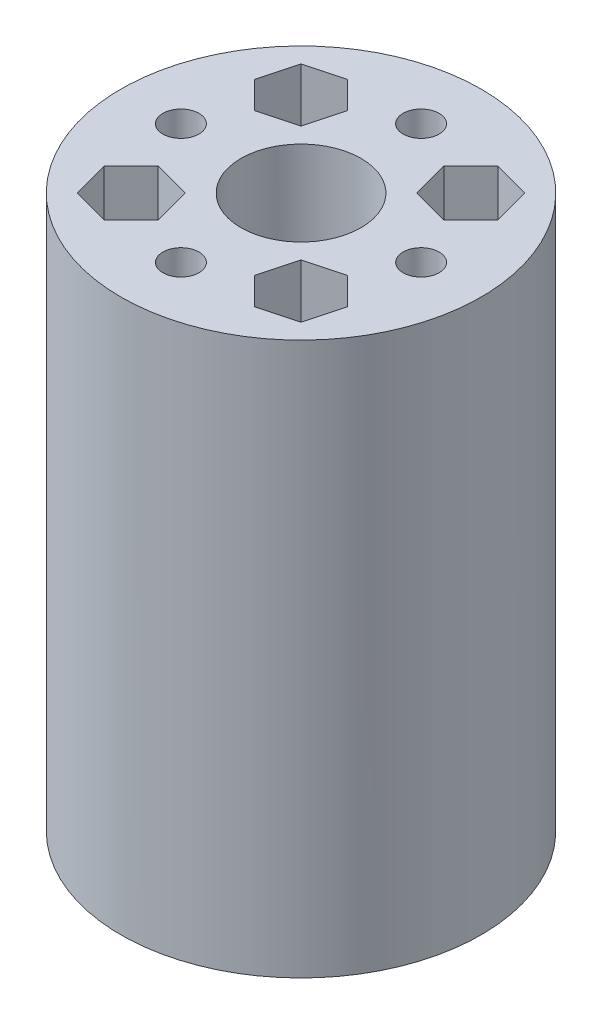
from build123d import *

# Parameters (mm, degrees)
SKETCH_1_R               = 15
SKETCH_1_R_2             = 5
EXTRUDE_4_DEPTH          = 3
SKETCH_1_R_3             = 3.5
SKETCH_1_R_4             = 2.1
EXTRUDE_4_2_DEPTH        = 3
EXTRUDE_5_DEPTH          = 3
PATTERN_CIRCULAR_2_COUNT = 4
SKETCH_6_R               = 3.5
SKETCH_6_R_2             = 2.1
EXTRUDE_6_DEPTH          = 3
PATTERN_CIRCULAR_3_COUNT = 4
SKETCH_7_R               = 15
SKETCH_7_R_2             = 5
EXTRUDE_7_DEPTH          = 46
CUT_EXTRUDE_1_DEPTH      = 46
PATTERN_CIRCULAR_4_COUNT = 4
SKETCH_11_R              = 1.5
CUT_EXTRUDE_2_DEPTH      = 3
PATTERN_CIRCULAR_5_COUNT = 4
EXTRUDE_8_DEPTH          = 3
EXTRUDE_9_DEPTH          = 3
EXTRUDE_10_DEPTH         = 3
EXTRUDE_11_DEPTH         = 3
EXTRUDE_13_DEPTH         = 3
EXTRUDE_14_DEPTH         = 3
CUT_EXTRUDE_3_DEPTH      = 2.5
SKETCH_19_R              = 1.5
CUT_EXTRUDE_4_DEPTH      = 2.5
SKETCH_20_R              = 1.5
CUT_EXTRUDE_5_DEPTH      = 2.5
SKETCH_21_R              = 15
SKETCH_21_R_2            = 5
EXTRUDE_15_DEPTH         = 3
SKETCH_22_R              = 1.5
CUT_EXTRUDE_6_DEPTH      = 3
PATTERN_CIRCULAR_6_COUNT = 4
EXTRUDE_16_DEPTH         = 3
CUT_EXTRUDE_7_DEPTH      = 3
SKETCH_25_R              = 15
SKETCH_25_R_2            = 5
EXTRUDE_17_DEPTH         = 43
SKETCH_27_R              = 1.5
CUT_EXTRUDE_8_DEPTH      = 46
SKETCH_28_R              = 2.75
CUT_EXTRUDE_9_DEPTH      = 43
SKETCH_29_R              = 1.5
CUT_EXTRUDE_10_DEPTH     = 46
PATTERN_CIRCULAR_7_COUNT = 4
CUT_EXTRUDE_11_DEPTH     = 43
PATTERN_CIRCULAR_8_COUNT = 4
SKETCH_31_R              = 35.862393663
CUT_EXTRUDE_12_DEPTH     = 100


with BuildPart() as part:
    # 草图1 → 凸台-拉伸4 (new body)
    with BuildSketch(Plane(origin=(0, 0, 0), x_dir=(1, 0, 0), z_dir=(0, 1, 0))):
        with Locations((-5.372895461, -8.931727747)):
            Circle(SKETCH_1_R)
        with Locations((-5.372895461, -8.931727747)):
            Circle(SKETCH_1_R_2, mode=Mode.SUBTRACT)
    extrude(amount=EXTRUDE_4_DEPTH)



with BuildPart() as body_2:
    # 草图1 → Extrude 4 2 (new body)
    with BuildSketch(Plane(origin=(0, 0, 0), x_dir=(1, 0, 0), z_dir=(0, 1, 0))):
        with Locations((-22.372895461, 8.068272253)):
            Circle(SKETCH_1_R_3)
        with Locations((-22.372895461, 8.068272253)):
            Circle(SKETCH_1_R_4, mode=Mode.SUBTRACT)
    extrude(amount=EXTRUDE_4_2_DEPTH)


with BuildPart() as part_1:
    add(part.part)

    add(body_2.part)  # 凸台-拉伸5 merges body 2
    # 草图5 → 凸台-拉伸5 (add)
    with BuildSketch(Plane(origin=(0, 0, 0), x_dir=(1, 0, 0), z_dir=(0, 1, 0))):
        Polygon((-22.372895461, 4.568272253), (-10.372895461, -8.931727747), (-10.372895461, -3.931727747), (-5.372895461, -3.931727747), (-18.872895461, 8.068272253), align=None)
    extrude_5 = extrude(amount=EXTRUDE_5_DEPTH)

    # 阵列(圆周)2: 凸台-拉伸5 ×4 about axis
    pattern_circular_2_axis = Axis((-5.372895461, 0, 8.931727747), (0, 1, 0))
    for i in range(1, PATTERN_CIRCULAR_2_COUNT):
        add(extrude_5.rotate(pattern_circular_2_axis, i * 360 / PATTERN_CIRCULAR_2_COUNT))

    # 草图6 → 凸台-拉伸6 (add)
    with BuildSketch(Plane(origin=(0, 3, 0), x_dir=(1, 0, 0), z_dir=(0, 1, 0))):
        with Locations((11.627104539, 8.068272253)):
            Circle(SKETCH_6_R)
        with Locations((11.627104539, 8.068272253)):
            Circle(SKETCH_6_R_2, mode=Mode.SUBTRACT)
    extrude_6 = extrude(amount=-EXTRUDE_6_DEPTH)

    # 阵列(圆周)3: 凸台-拉伸6 ×4 about axis
    pattern_circular_3_axis = Axis((-5.372895461, 0, 8.931727747), (0, 1, 0))
    for i in range(1, PATTERN_CIRCULAR_3_COUNT):
        add(extrude_6.rotate(pattern_circular_3_axis, i * 360 / PATTERN_CIRCULAR_3_COUNT))

    # 草图7 → 凸台-拉伸7 (add)
    with BuildSketch(Plane.XZ):
        with Locations((-5.372895461, 8.931727747)):
            Circle(SKETCH_7_R)
        with Locations((-5.372895461, 8.931727747)):
            Circle(SKETCH_7_R_2, mode=Mode.SUBTRACT)
    extrude(amount=EXTRUDE_7_DEPTH)

    # 草图9 → 切除-拉伸1 (cut)
    with BuildSketch(Plane(origin=(0, 3, 0), x_dir=(1, 0, 0), z_dir=(0, 1, 0))):
        Polygon((0.876311502, -19.070022006), (-1.369054096, -16.824656408), (-0.547193246, -13.757429961), (2.520033201, -12.935569112), (4.765398798, -15.180934709), (3.943537949, -18.248161156), align=None)
    cut_extrude_1 = extrude(amount=-CUT_EXTRUDE_1_DEPTH, mode=Mode.SUBTRACT)

    # 阵列(圆周)4: 切除-拉伸1 ×4 about axis
    pattern_circular_4_axis = Axis((-5.372895461, 0, 8.931727747), (0, 1, 0))
    for i in range(1, PATTERN_CIRCULAR_4_COUNT):
        add(cut_extrude_1.rotate(pattern_circular_4_axis, i * 360 / PATTERN_CIRCULAR_4_COUNT), mode=Mode.SUBTRACT)

    # 草图11 → 切除-拉伸2 (cut)
    with BuildSketch(Plane(origin=(0, -43, 0), x_dir=(1, 0, 0), z_dir=(0, 1, 0))):
        with Locations((1.698172351, -1.860659935)):
            Circle(SKETCH_11_R)
    cut_extrude_2 = extrude(amount=-CUT_EXTRUDE_2_DEPTH, mode=Mode.SUBTRACT)

    # 阵列(圆周)5: 切除-拉伸2 ×4 about axis
    pattern_circular_5_axis = Axis((-5.372895461, 0, 8.931727747), (0, 1, 0))
    for i in range(1, PATTERN_CIRCULAR_5_COUNT):
        add(cut_extrude_2.rotate(pattern_circular_5_axis, i * 360 / PATTERN_CIRCULAR_5_COUNT), mode=Mode.SUBTRACT)

    # 草图12 → 凸台-拉伸8 (add)
    with BuildSketch(Plane(origin=(0, 3, 0), x_dir=(1, 0, 0), z_dir=(0, 1, 0))):
        Polygon((15.127104539, 8.068272253), (15.127104539, -25.931727747), (11.627104539, -22.431727747), (11.627104539, 4.568272253), align=None)
    extrude(amount=-EXTRUDE_8_DEPTH)

    # 草图13 → 凸台-拉伸9 (add)
    with BuildSketch(Plane(origin=(0, 3, 0), x_dir=(1, 0, 0), z_dir=(0, 1, 0))):
        Polygon((11.627104539, 11.568272253), (-22.372895461, 11.568272253), (-18.872895461, 8.068272253), (8.127104539, 8.068272253), align=None)
    extrude(amount=-EXTRUDE_9_DEPTH)

    # 草图14 → 凸台-拉伸10 (add)
    with BuildSketch(Plane(origin=(0, 3, 0), x_dir=(1, 0, 0), z_dir=(0, 1, 0))):
        Polygon((-25.872895461, 8.068272253), (-25.872895461, -25.931727747), (-22.372895461, -22.431727747), (-22.372895461, 4.568272253), align=None)
    extrude(amount=-EXTRUDE_10_DEPTH)

    # 草图15 → 凸台-拉伸11 (add)
    with BuildSketch(Plane(origin=(0, 3, 0), x_dir=(1, 0, 0), z_dir=(0, 1, 0))):
        Polygon((-22.372895461, -29.431727747), (11.627104539, -29.431727747), (8.127104539, -25.931727747), (-18.872895461, -25.931727747), align=None)
    extrude(amount=-EXTRUDE_11_DEPTH)

    # 草图16 → 凸台-拉伸13 (add)
    with BuildSketch(Plane.XZ):
        Polygon((-10.747895461, -4.193272253), (0.002104539, -4.193272253), (5.163560245, -8.068272253), (4.99115505, -11.568272253), (0.002104539, -14.943272253), (-10.747895461, -14.943272253), (-15.736945971, -11.568272253), (-15.909351166, -8.068272253), align=None)
        Polygon((-7.57246898, -9.568272253), (-9.16018222, -6.818272253), (-12.335608701, -6.818272253), (-13.923321941, -9.568272253), (-12.335608701, -12.318272253), (-9.16018222, -12.318272253), align=None, mode=Mode.SUBTRACT)
        Polygon((3.17753102, -9.568272253), (1.58981778, -6.818272253), (-1.585608701, -6.818272253), (-3.173321941, -9.568272253), (-1.585608701, -12.318272253), (1.58981778, -12.318272253), align=None, mode=Mode.SUBTRACT)
    extrude(amount=-EXTRUDE_13_DEPTH)

    # 草图18 → 凸台-拉伸14 (add)
    with BuildSketch(Plane.XZ):
        Polygon((-7.57246898, -9.568272253), (-9.16018222, -6.818272253), (-12.335608701, -6.818272253), (-13.923321941, -9.568272253), (-12.335608701, -12.318272253), (-9.16018222, -12.318272253), align=None)
        Polygon((3.17753102, -9.568272253), (1.58981778, -6.818272253), (-1.585608701, -6.818272253), (-3.173321941, -9.568272253), (-1.585608701, -12.318272253), (1.58981778, -12.318272253), align=None)
    extrude(amount=-EXTRUDE_14_DEPTH)

    # 草图17 → 切除-拉伸3 (cut)
    with BuildSketch(Plane.XZ):
        Polygon((-7.57246898, -9.568272253), (-9.16018222, -6.818272253), (-12.335608701, -6.818272253), (-13.923321941, -9.568272253), (-12.335608701, -12.318272253), (-9.16018222, -12.318272253), align=None)
        Polygon((3.17753102, -9.568272253), (1.58981778, -6.818272253), (-1.585608701, -6.818272253), (-3.173321941, -9.568272253), (-1.585608701, -12.318272253), (1.58981778, -12.318272253), align=None)
    extrude(amount=-CUT_EXTRUDE_3_DEPTH, mode=Mode.SUBTRACT)

    # 草图19 → 切除-拉伸4 (cut)
    with BuildSketch(Plane.XZ.offset(-2.5)):
        with Locations((0.002104539, -9.568272253)):
            Circle(SKETCH_19_R)
    extrude(amount=-CUT_EXTRUDE_4_DEPTH, mode=Mode.SUBTRACT)

    # 草图20 → 切除-拉伸5 (cut)
    with BuildSketch(Plane.XZ.offset(-2.5)):
        with Locations((-10.747895461, -9.568272253)):
            Circle(SKETCH_20_R)
    extrude(amount=-CUT_EXTRUDE_5_DEPTH, mode=Mode.SUBTRACT)

    # 草图8 → 凸台-拉伸16 (add)
    with BuildSketch(Plane.XZ.offset(46)):
        Polygon((3.943537949, 18.248161156), (0.876311502, 19.070022006), (-1.369054096, 16.824656408), (-0.547193246, 13.757429961), (2.520033201, 12.935569112), (4.765398798, 15.180934709), align=None)
    extrude(amount=EXTRUDE_16_DEPTH)

    # 草图24 → 切除-拉伸7 (cut)
    with BuildSketch(Plane.XZ.offset(49)):
        Polygon((4.765398798, 15.180934709), (3.943537949, 18.248161156), (0.876311502, 19.070022006), (-1.369054096, 16.824656408), (-0.547193246, 13.757429961), (2.520033201, 12.935569112), align=None)
    extrude(amount=-CUT_EXTRUDE_7_DEPTH, mode=Mode.SUBTRACT)

    # 草图31 → 切除-拉伸12 (cut)
    with BuildSketch(Plane(origin=(0, 3, 0), x_dir=(1, 0, 0), z_dir=(0, 1, 0))):
        with Locations((-6.301118326, -7.45969761)):
            Circle(SKETCH_31_R)
    extrude(amount=-CUT_EXTRUDE_12_DEPTH, mode=Mode.SUBTRACT)


with BuildPart() as body_2_2:
    # 草图21 → 凸台-拉伸15 (new body)
    with BuildSketch(Plane(origin=(0, 0, 0), x_dir=(1, 0, 0), z_dir=(0, 1, 0))):
        with Locations((59.665545214, -8.931727747)):
            Circle(SKETCH_21_R)
        with Locations((59.665545214, -8.931727747)):
            Circle(SKETCH_21_R_2, mode=Mode.SUBTRACT)
    extrude(amount=EXTRUDE_15_DEPTH)

    # 草图22 → 切除-拉伸6 (cut)
    with BuildSketch(Plane.XZ):
        with Locations((59.665545214, 18.931727747)):
            Circle(SKETCH_22_R)
    cut_extrude_6 = extrude(amount=-CUT_EXTRUDE_6_DEPTH, mode=Mode.SUBTRACT)

    # 阵列(圆周)6: 切除-拉伸6 ×4 about axis
    pattern_circular_6_axis = Axis((59.665545214, 0, 8.931727747), (0, 1, 0))
    for i in range(1, PATTERN_CIRCULAR_6_COUNT):
        add(cut_extrude_6.rotate(pattern_circular_6_axis, i * 360 / PATTERN_CIRCULAR_6_COUNT), mode=Mode.SUBTRACT)

    # 草图25 → 凸台-拉伸17 (add)
    with BuildSketch(Plane.XZ):
        with Locations((59.665545214, 8.931727747)):
            Circle(SKETCH_25_R)
        with Locations((59.665545214, 8.931727747)):
            Circle(SKETCH_25_R_2, mode=Mode.SUBTRACT)
    extrude(amount=EXTRUDE_17_DEPTH)

    # 草图27 → 切除-拉伸8 (cut)
    with BuildSketch(Plane(origin=(0, 3, 0), x_dir=(1, 0, 0), z_dir=(0, 1, 0))):
        with Locations((59.665545214, 1.068272253)):
            Circle(SKETCH_27_R)
        with Locations((69.665545214, -8.931727747)):
            Circle(SKETCH_27_R)
        with Locations((59.665545214, -18.931727747)):
            Circle(SKETCH_27_R)
        with Locations((49.665545214, -8.931727747)):
            Circle(SKETCH_27_R)
    extrude(amount=-CUT_EXTRUDE_8_DEPTH, mode=Mode.SUBTRACT)

    # 草图28 → 切除-拉伸9 (cut)
    with BuildSketch(Plane.XZ.offset(43)):
        with Locations((59.665545214, 18.931727747)):
            Circle(SKETCH_28_R)
        with Locations((49.665545214, 8.931727747)):
            Circle(SKETCH_28_R)
        with Locations((59.665545214, -1.068272253)):
            Circle(SKETCH_28_R)
        with Locations((69.665545214, 8.931727747)):
            Circle(SKETCH_28_R)
    extrude(amount=-CUT_EXTRUDE_9_DEPTH, mode=Mode.SUBTRACT)

    # 草图29 → 切除-拉伸10 (cut)
    with BuildSketch(Plane(origin=(0, 3, 0), x_dir=(1, 0, 0), z_dir=(0, 1, 0))):
        with Locations((66.736613026, -1.860659935)):
            Circle(SKETCH_29_R)
    cut_extrude_10 = extrude(amount=-CUT_EXTRUDE_10_DEPTH, mode=Mode.SUBTRACT)

    # 阵列(圆周)7: 切除-拉伸10 ×4 about axis
    pattern_circular_7_axis = Axis((59.665545214, 0, 8.931727747), (0, 1, 0))
    for i in range(1, PATTERN_CIRCULAR_7_COUNT):
        add(cut_extrude_10.rotate(pattern_circular_7_axis, i * 360 / PATTERN_CIRCULAR_7_COUNT), mode=Mode.SUBTRACT)

    # 草图30 → 切除-拉伸11 (cut)
    with BuildSketch(Plane(origin=(0, 3, 0), x_dir=(1, 0, 0), z_dir=(0, 1, 0))):
        Polygon((64.491247429, -4.106025533), (67.558473876, -4.927886382), (69.803839473, -2.682520785), (68.981978624, 0.384705662), (65.914752177, 1.206566512), (63.669386579, -1.038799086), align=None)
    cut_extrude_11 = extrude(amount=-CUT_EXTRUDE_11_DEPTH, mode=Mode.SUBTRACT)

    # 阵列(圆周)8: 切除-拉伸11 ×4 about axis
    pattern_circular_8_axis = Axis((59.665545214, 0, 8.931727747), (0, 1, 0))
    for i in range(1, PATTERN_CIRCULAR_8_COUNT):
        add(cut_extrude_11.rotate(pattern_circular_8_axis, i * 360 / PATTERN_CIRCULAR_8_COUNT), mode=Mode.SUBTRACT)


solid = body_2_2.part
